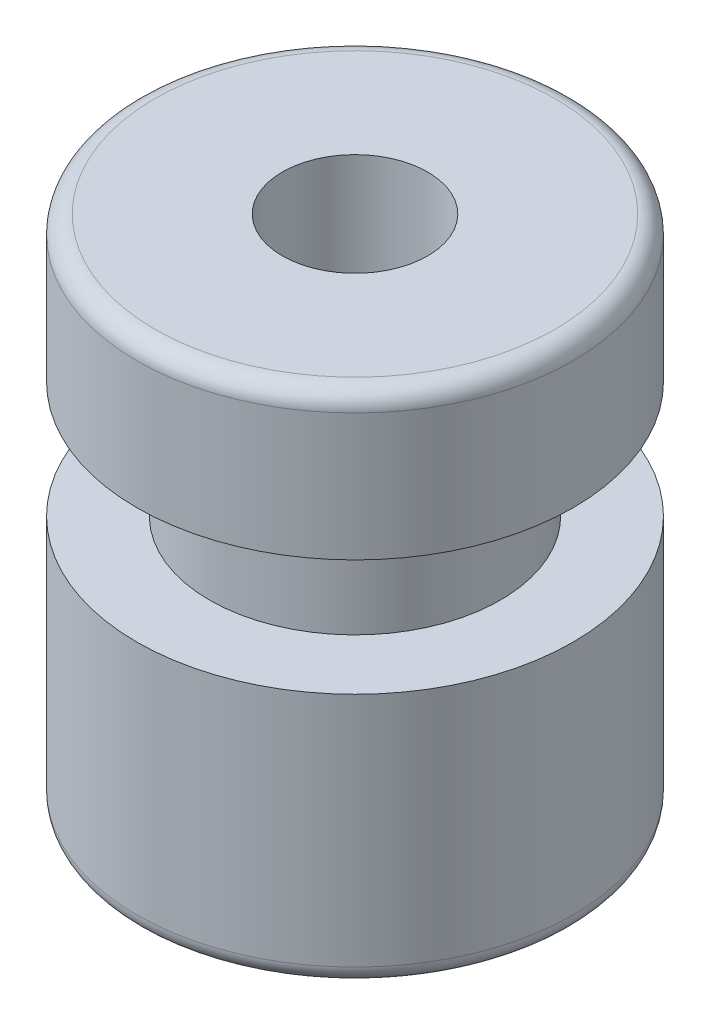
from build123d import *

# Parameters (mm, degrees)
SKETCH1_R           = 3
SKETCH1_R_2         = 1
BOSS_EXTRUDE1_DEPTH = 3.5
SKETCH2_R           = 2
SKETCH2_R_2         = 1
BOSS_EXTRUDE2_DEPTH = 1.6
SKETCH3_R           = 3
SKETCH3_R_2         = 1
BOSS_EXTRUDE3_DEPTH = 2
FILLET1_R           = 0.25


with BuildPart() as part:
    # Sketch1 → Boss-Extrude1 (new body)
    with BuildSketch(Plane(origin=(0, 0, 0), x_dir=(1, 0, 0), z_dir=(0, 1, 0))):
        Circle(SKETCH1_R)
        Circle(SKETCH1_R_2, mode=Mode.SUBTRACT)
    extrude(amount=BOSS_EXTRUDE1_DEPTH)

    # Sketch2 → Boss-Extrude2 (add)
    with BuildSketch(Plane(origin=(0, 3.5, 0), x_dir=(1, 0, 0), z_dir=(0, 1, 0))):
        Circle(SKETCH2_R)
        Circle(SKETCH2_R_2, mode=Mode.SUBTRACT)
    extrude(amount=BOSS_EXTRUDE2_DEPTH)

    # Sketch3 → Boss-Extrude3 (add)
    with BuildSketch(Plane(origin=(0, 5.1, 0), x_dir=(1, 0, 0), z_dir=(0, 1, 0))):
        Circle(SKETCH3_R)
        Circle(SKETCH3_R_2, mode=Mode.SUBTRACT)
    extrude(amount=BOSS_EXTRUDE3_DEPTH)

    # Fillet1
    fillet1_edges = [part.edges().sort_by_distance(p)[0] for p in [
        (-3, 7.1, 0),
        (-3, 0, 0),
    ]]
    fillet(fillet1_edges, radius=FILLET1_R)


solid = part.part
